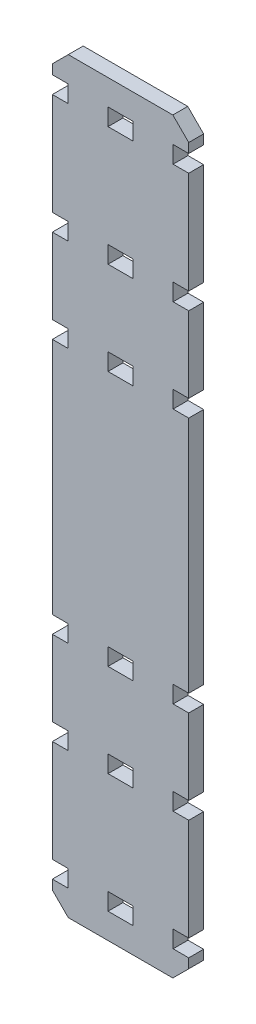
from build123d import *

# Parameters (mm, degrees)
SKETCH1_W           = 8
SKETCH1_H           = 5.461
BOSS_EXTRUDE1_DEPTH = 4.7625
CHAMFER1_SIZE       = 5.08


with BuildPart() as part:
    # Sketch1 → Boss-Extrude1 (new body)
    with BuildSketch(Plane.XY):
        Polygon((43.598645263, 119.489), (0, 119.489), (0, 111.361), (5, 111.361), (5, 105.9), (0, 105.9), (0, 73.261), (5, 73.261), (5, 67.8), (0, 67.8), (0, 43.561), (5, 43.561), (5, 38.1), (0, 38.1), (0, -38.1), (5, -38.1), (5, -43.561), (0, -43.561), (0, -67.8), (5, -67.8), (5, -73.261), (0, -73.261), (0, -105.9), (5, -105.9), (5, -111.361), (0, -111.361), (0, -119.489), (43.598645263, -119.489), (43.598645263, -111.361), (38.598645263, -111.361), (38.598645263, -105.9), (43.598645263, -105.9), (43.598645263, -73.261), (38.598645263, -73.261), (38.598645263, -67.8), (43.598645263, -67.8), (43.598645263, -43.561), (38.598645263, -43.561), (38.598645263, -38.1), (43.598645263, -38.1), (43.598645263, 38.1), (38.598645263, 38.1), (38.598645263, 43.561), (43.598645263, 43.561), (43.598645263, 67.8), (38.598645263, 67.8), (38.598645263, 73.261), (43.598645263, 73.261), (43.598645263, 105.9), (38.598645263, 105.9), (38.598645263, 111.361), (43.598645263, 111.361), align=None)
        with Locations((21.799322631, 108.6305)):
            Rectangle(SKETCH1_W, SKETCH1_H, mode=Mode.SUBTRACT)
        with Locations((21.799322631, 70.5305)):
            Rectangle(SKETCH1_W, SKETCH1_H, mode=Mode.SUBTRACT)
        with Locations((21.799322631, 40.8305)):
            Rectangle(SKETCH1_W, SKETCH1_H, mode=Mode.SUBTRACT)
        with Locations((21.799322631, -40.8305)):
            Rectangle(SKETCH1_W, SKETCH1_H, mode=Mode.SUBTRACT)
        with Locations((21.799322631, -70.5305)):
            Rectangle(SKETCH1_W, SKETCH1_H, mode=Mode.SUBTRACT)
        with Locations((21.799322631, -108.6305)):
            Rectangle(SKETCH1_W, SKETCH1_H, mode=Mode.SUBTRACT)
    extrude(amount=BOSS_EXTRUDE1_DEPTH)

    # Chamfer1
    chamfer1_edges = [part.edges().sort_by_distance(p)[0] for p in [
        (43.598645263, 119.489, 2.38125),
        (0, 119.489, 2.38125),
        (43.598645263, -119.489, 2.38125),
        (0, -119.489, 2.38125),
    ]]
    chamfer(chamfer1_edges, length=CHAMFER1_SIZE)


solid = part.part
